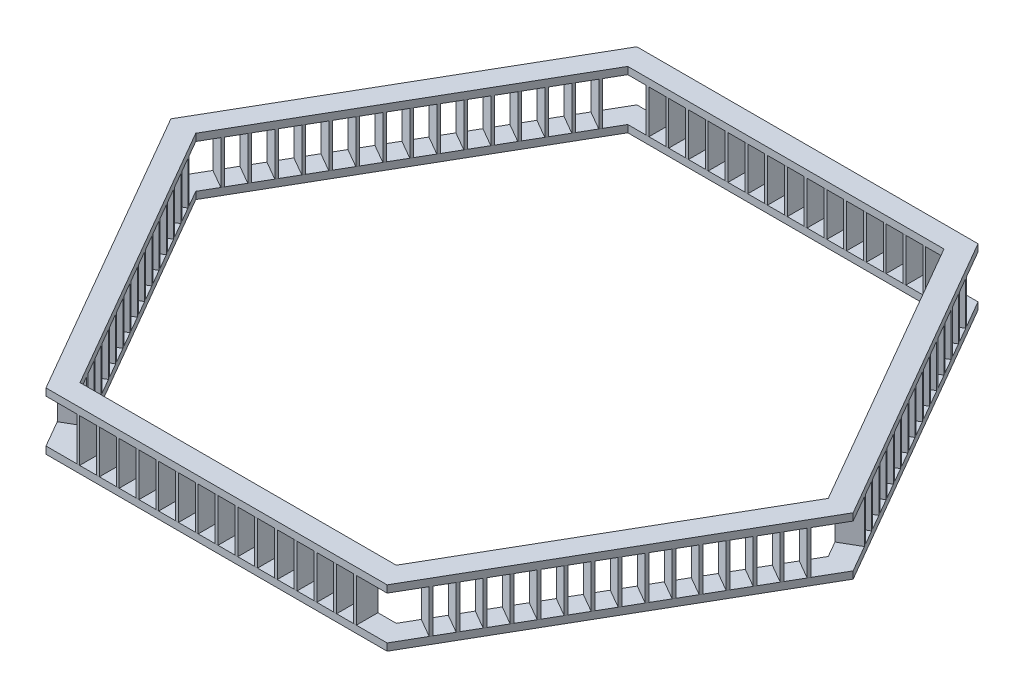
from build123d import *

# Parameters (mm, degrees)
EXTRUDE_2_DEPTH             = 50
SKETCH_2_W                  = 20
SKETCH_2_H                  = 150
EXTRUDE_3_DEPTH             = 300
EXTRUDE_3_2_DEPTH           = 300
EXTRUDE_3_3_DEPTH           = 300
EXTRUDE_3_4_DEPTH           = 300
EXTRUDE_3_5_DEPTH           = 300
EXTRUDE_3_6_DEPTH           = 300
EXTRUDE_3_7_DEPTH           = 300
EXTRUDE_3_8_DEPTH           = 300
EXTRUDE_3_9_DEPTH           = 300
EXTRUDE_3_10_DEPTH          = 300
EXTRUDE_3_11_DEPTH          = 300
EXTRUDE_3_12_DEPTH          = 300
EXTRUDE_3_13_DEPTH          = 300
EXTRUDE_3_14_DEPTH          = 300
EXTRUDE_3_15_DEPTH          = 300
PATTERN_CIRCULAR_2_COUNT    = 6
PATTERN_CIRCULAR_2_2_COUNT  = 6
PATTERN_CIRCULAR_2_3_COUNT  = 6
PATTERN_CIRCULAR_2_4_COUNT  = 6
PATTERN_CIRCULAR_2_5_COUNT  = 6
PATTERN_CIRCULAR_2_6_COUNT  = 6
PATTERN_CIRCULAR_2_7_COUNT  = 6
PATTERN_CIRCULAR_2_8_COUNT  = 6
PATTERN_CIRCULAR_2_9_COUNT  = 6
PATTERN_CIRCULAR_2_10_COUNT = 6
PATTERN_CIRCULAR_2_11_COUNT = 6
PATTERN_CIRCULAR_2_12_COUNT = 6
PATTERN_CIRCULAR_2_13_COUNT = 6
PATTERN_CIRCULAR_2_14_COUNT = 6
PATTERN_CIRCULAR_2_15_COUNT = 6
EXTRUDE_5_DEPTH             = 50


with BuildPart() as part:
    # 草图1 → 凸台-拉伸2 (new body)
    with BuildSketch(Plane(origin=(0, 0, 0), x_dir=(1, 0, 0), z_dir=(0, 1, 0))):
        Polygon((-1186.602540378, -2055.255888326), (1186.602540378, -2055.255888326), (2373.205080757, 0), (1186.602540378, 2055.255888326), (-1186.602540378, 2055.255888326), (-2373.205080757, 0), align=None)
        Polygon((-1100, -1905.255888326), (1100, -1905.255888326), (2200, 0), (1100, 1905.255888326), (-1100, 1905.255888326), (-2200, 0), align=None, mode=Mode.SUBTRACT)
    extrude(amount=EXTRUDE_2_DEPTH)


with BuildPart() as body_2:
    # 草图2 → 凸台-拉伸3 (new body)
    with BuildSketch(Plane(origin=(0, 50, 0), x_dir=(1, 0, 0), z_dir=(0, 1, 0))):
        with Locations((137.5, 1980.255888326)):
            Rectangle(SKETCH_2_W, SKETCH_2_H)
    extrude(amount=EXTRUDE_3_DEPTH)

    # Pattern Circular 2 14: body 2 ×6 about axis
    pattern_circular_2_14_axis = Axis((0, 0, 0), (0, 1, 0))


with BuildPart() as body_3:
    # 草图2 → Extrude 3 2 (new body)
    with BuildSketch(Plane(origin=(0, 50, 0), x_dir=(1, 0, 0), z_dir=(0, 1, 0))):
        with Locations((412.5, 1980.255888326)):
            Rectangle(SKETCH_2_W, SKETCH_2_H)
    extrude(amount=EXTRUDE_3_2_DEPTH)

    # Pattern Circular 2 9: body 3 ×6 about axis
    pattern_circular_2_9_axis = Axis((0, 0, 0), (0, 1, 0))


with BuildPart() as body_4:
    # 草图2 → Extrude 3 3 (new body)
    with BuildSketch(Plane(origin=(0, 50, 0), x_dir=(1, 0, 0), z_dir=(0, 1, 0))):
        with Locations((687.5, 1980.255888326)):
            Rectangle(SKETCH_2_W, SKETCH_2_H)
    extrude(amount=EXTRUDE_3_3_DEPTH)

    # Pattern Circular 2 15: body 4 ×6 about axis
    pattern_circular_2_15_axis = Axis((0, 0, 0), (0, 1, 0))


with BuildPart() as body_5:
    # 草图2 → Extrude 3 4 (new body)
    with BuildSketch(Plane(origin=(0, 50, 0), x_dir=(1, 0, 0), z_dir=(0, 1, 0))):
        with Locations((962.5, 1980.255888326)):
            Rectangle(SKETCH_2_W, SKETCH_2_H)
    extrude(amount=EXTRUDE_3_4_DEPTH)

    # Pattern Circular 2 8: body 5 ×6 about axis
    pattern_circular_2_8_axis = Axis((0, 0, 0), (0, 1, 0))


with BuildPart() as body_6:
    # 草图2 → Extrude 3 5 (new body)
    with BuildSketch(Plane(origin=(0, 50, 0), x_dir=(1, 0, 0), z_dir=(0, 1, 0))):
        with Locations((-412.5, 1980.255888326)):
            Rectangle(SKETCH_2_W, SKETCH_2_H)
    extrude(amount=EXTRUDE_3_5_DEPTH)

    # Pattern Circular 2 12: body 6 ×6 about axis
    pattern_circular_2_12_axis = Axis((0, 0, 0), (0, 1, 0))


with BuildPart() as body_7:
    # 草图2 → Extrude 3 6 (new body)
    with BuildSketch(Plane(origin=(0, 50, 0), x_dir=(1, 0, 0), z_dir=(0, 1, 0))):
        with Locations((-962.5, 1980.255888326)):
            Rectangle(SKETCH_2_W, SKETCH_2_H)
    extrude(amount=EXTRUDE_3_6_DEPTH)

    # Pattern Circular 2 10: body 7 ×6 about axis
    pattern_circular_2_10_axis = Axis((0, 0, 0), (0, 1, 0))


with BuildPart() as body_8:
    # 草图2 → Extrude 3 7 (new body)
    with BuildSketch(Plane(origin=(0, 50, 0), x_dir=(1, 0, 0), z_dir=(0, 1, 0))):
        with Locations((-687.5, 1980.255888326)):
            Rectangle(SKETCH_2_W, SKETCH_2_H)
    extrude(amount=EXTRUDE_3_7_DEPTH)

    # Pattern Circular 2 11: body 8 ×6 about axis
    pattern_circular_2_11_axis = Axis((0, 0, 0), (0, 1, 0))


with BuildPart() as body_9:
    # 草图2 → Extrude 3 8 (new body)
    with BuildSketch(Plane(origin=(0, 50, 0), x_dir=(1, 0, 0), z_dir=(0, 1, 0))):
        with Locations((-137.5, 1980.255888326)):
            Rectangle(SKETCH_2_W, SKETCH_2_H)
    extrude(amount=EXTRUDE_3_8_DEPTH)

    # Pattern Circular 2 13: body 9 ×6 about axis
    pattern_circular_2_13_axis = Axis((0, 0, 0), (0, 1, 0))


with BuildPart() as body_10:
    # 草图2 → Extrude 3 9 (new body)
    with BuildSketch(Plane(origin=(0, 50, 0), x_dir=(1, 0, 0), z_dir=(0, 1, 0))):
        with Locations((825, 1980.255888326)):
            Rectangle(SKETCH_2_W, SKETCH_2_H)
    extrude(amount=EXTRUDE_3_9_DEPTH)

    # 阵列(圆周)2: body 10 ×6 about axis
    pattern_circular_2_axis = Axis((0, 0, 0), (0, 1, 0))


with BuildPart() as body_11:
    # 草图2 → Extrude 3 10 (new body)
    with BuildSketch(Plane(origin=(0, 50, 0), x_dir=(1, 0, 0), z_dir=(0, 1, 0))):
        with Locations((275, 1980.255888326)):
            Rectangle(SKETCH_2_W, SKETCH_2_H)
    extrude(amount=EXTRUDE_3_10_DEPTH)

    # Pattern Circular 2 3: body 11 ×6 about axis
    pattern_circular_2_3_axis = Axis((0, 0, 0), (0, 1, 0))


with BuildPart() as body_12:
    # 草图2 → Extrude 3 11 (new body)
    with BuildSketch(Plane(origin=(0, 50, 0), x_dir=(1, 0, 0), z_dir=(0, 1, 0))):
        with Locations((550, 1980.255888326)):
            Rectangle(SKETCH_2_W, SKETCH_2_H)
    extrude(amount=EXTRUDE_3_11_DEPTH)

    # Pattern Circular 2 2: body 12 ×6 about axis
    pattern_circular_2_2_axis = Axis((0, 0, 0), (0, 1, 0))


with BuildPart() as body_13:
    # 草图2 → Extrude 3 12 (new body)
    with BuildSketch(Plane(origin=(0, 50, 0), x_dir=(1, 0, 0), z_dir=(0, 1, 0))):
        with Locations((0, 1980.255888326)):
            Rectangle(SKETCH_2_W, SKETCH_2_H)
    extrude(amount=EXTRUDE_3_12_DEPTH)

    # Pattern Circular 2 4: body 13 ×6 about axis
    pattern_circular_2_4_axis = Axis((0, 0, 0), (0, 1, 0))


with BuildPart() as body_14:
    # 草图2 → Extrude 3 13 (new body)
    with BuildSketch(Plane(origin=(0, 50, 0), x_dir=(1, 0, 0), z_dir=(0, 1, 0))):
        with Locations((-275, 1980.255888326)):
            Rectangle(SKETCH_2_W, SKETCH_2_H)
    extrude(amount=EXTRUDE_3_13_DEPTH)

    # Pattern Circular 2 5: body 14 ×6 about axis
    pattern_circular_2_5_axis = Axis((0, 0, 0), (0, 1, 0))


with BuildPart() as body_15:
    # 草图2 → Extrude 3 14 (new body)
    with BuildSketch(Plane(origin=(0, 50, 0), x_dir=(1, 0, 0), z_dir=(0, 1, 0))):
        with Locations((-550, 1980.255888326)):
            Rectangle(SKETCH_2_W, SKETCH_2_H)
    extrude(amount=EXTRUDE_3_14_DEPTH)

    # Pattern Circular 2 6: body 15 ×6 about axis
    pattern_circular_2_6_axis = Axis((0, 0, 0), (0, 1, 0))


with BuildPart() as body_16:
    # 草图2 → Extrude 3 15 (new body)
    with BuildSketch(Plane(origin=(0, 50, 0), x_dir=(1, 0, 0), z_dir=(0, 1, 0))):
        with Locations((-825, 1980.255888326)):
            Rectangle(SKETCH_2_W, SKETCH_2_H)
    extrude(amount=EXTRUDE_3_15_DEPTH)

    # Pattern Circular 2 7: body 16 ×6 about axis
    pattern_circular_2_7_axis = Axis((0, 0, 0), (0, 1, 0))


with BuildPart() as body_10_1:
    add(body_10.part)
    for i in range(1, PATTERN_CIRCULAR_2_COUNT):
        add(body_10.part.rotate(pattern_circular_2_axis, i * 360 / PATTERN_CIRCULAR_2_COUNT))


with BuildPart() as body_12_1:
    add(body_12.part)
    for i in range(1, PATTERN_CIRCULAR_2_2_COUNT):
        add(body_12.part.rotate(pattern_circular_2_2_axis, i * 360 / PATTERN_CIRCULAR_2_2_COUNT))


with BuildPart() as body_11_1:
    add(body_11.part)
    for i in range(1, PATTERN_CIRCULAR_2_3_COUNT):
        add(body_11.part.rotate(pattern_circular_2_3_axis, i * 360 / PATTERN_CIRCULAR_2_3_COUNT))


with BuildPart() as body_13_1:
    add(body_13.part)
    for i in range(1, PATTERN_CIRCULAR_2_4_COUNT):
        add(body_13.part.rotate(pattern_circular_2_4_axis, i * 360 / PATTERN_CIRCULAR_2_4_COUNT))


with BuildPart() as body_14_1:
    add(body_14.part)
    for i in range(1, PATTERN_CIRCULAR_2_5_COUNT):
        add(body_14.part.rotate(pattern_circular_2_5_axis, i * 360 / PATTERN_CIRCULAR_2_5_COUNT))


with BuildPart() as body_15_1:
    add(body_15.part)
    for i in range(1, PATTERN_CIRCULAR_2_6_COUNT):
        add(body_15.part.rotate(pattern_circular_2_6_axis, i * 360 / PATTERN_CIRCULAR_2_6_COUNT))


with BuildPart() as body_16_1:
    add(body_16.part)
    for i in range(1, PATTERN_CIRCULAR_2_7_COUNT):
        add(body_16.part.rotate(pattern_circular_2_7_axis, i * 360 / PATTERN_CIRCULAR_2_7_COUNT))


with BuildPart() as body_5_1:
    add(body_5.part)
    for i in range(1, PATTERN_CIRCULAR_2_8_COUNT):
        add(body_5.part.rotate(pattern_circular_2_8_axis, i * 360 / PATTERN_CIRCULAR_2_8_COUNT))


with BuildPart() as body_3_1:
    add(body_3.part)
    for i in range(1, PATTERN_CIRCULAR_2_9_COUNT):
        add(body_3.part.rotate(pattern_circular_2_9_axis, i * 360 / PATTERN_CIRCULAR_2_9_COUNT))


with BuildPart() as body_7_1:
    add(body_7.part)
    for i in range(1, PATTERN_CIRCULAR_2_10_COUNT):
        add(body_7.part.rotate(pattern_circular_2_10_axis, i * 360 / PATTERN_CIRCULAR_2_10_COUNT))


with BuildPart() as body_8_1:
    add(body_8.part)
    for i in range(1, PATTERN_CIRCULAR_2_11_COUNT):
        add(body_8.part.rotate(pattern_circular_2_11_axis, i * 360 / PATTERN_CIRCULAR_2_11_COUNT))


with BuildPart() as body_6_1:
    add(body_6.part)
    for i in range(1, PATTERN_CIRCULAR_2_12_COUNT):
        add(body_6.part.rotate(pattern_circular_2_12_axis, i * 360 / PATTERN_CIRCULAR_2_12_COUNT))


with BuildPart() as body_9_1:
    add(body_9.part)
    for i in range(1, PATTERN_CIRCULAR_2_13_COUNT):
        add(body_9.part.rotate(pattern_circular_2_13_axis, i * 360 / PATTERN_CIRCULAR_2_13_COUNT))


with BuildPart() as body_2_1:
    add(body_2.part)
    for i in range(1, PATTERN_CIRCULAR_2_14_COUNT):
        add(body_2.part.rotate(pattern_circular_2_14_axis, i * 360 / PATTERN_CIRCULAR_2_14_COUNT))


    add(body_3_1.part)  # 凸台-拉伸5 merges body 3


with BuildPart() as body_4_1:
    add(body_4.part)
    for i in range(1, PATTERN_CIRCULAR_2_15_COUNT):
        add(body_4.part.rotate(pattern_circular_2_15_axis, i * 360 / PATTERN_CIRCULAR_2_15_COUNT))


with BuildPart() as body_2_2:
    add(body_2_1.part)

    add(body_4_1.part)  # 凸台-拉伸5 merges body 4

    add(body_5_1.part)  # 凸台-拉伸5 merges body 5

    add(body_6_1.part)  # 凸台-拉伸5 merges body 6

    add(body_7_1.part)  # 凸台-拉伸5 merges body 7

    add(body_8_1.part)  # 凸台-拉伸5 merges body 8

    add(body_9_1.part)  # 凸台-拉伸5 merges body 9
    # 草图5 → 凸台-拉伸5 (add)
    with BuildSketch(Plane(origin=(0, 350, 0), x_dir=(1, 0, 0), z_dir=(0, 1, 0))):
        Polygon((-2373.205080757, 0), (-1186.602540378, -2055.255888326), (1186.602540378, -2055.255888326), (2373.205080757, 0), (1186.602540378, 2055.255888326), (-1186.602540378, 2055.255888326), align=None)
        Polygon((-2200, 0), (-1100, -1905.255888326), (1100, -1905.255888326), (2200, 0), (1100, 1905.255888326), (-1100, 1905.255888326), align=None, mode=Mode.SUBTRACT)
    extrude(amount=EXTRUDE_5_DEPTH)


solid = Compound([part.part, body_10_1.part, body_12_1.part, body_11_1.part, body_13_1.part, body_14_1.part, body_15_1.part, body_16_1.part, body_2_2.part])
